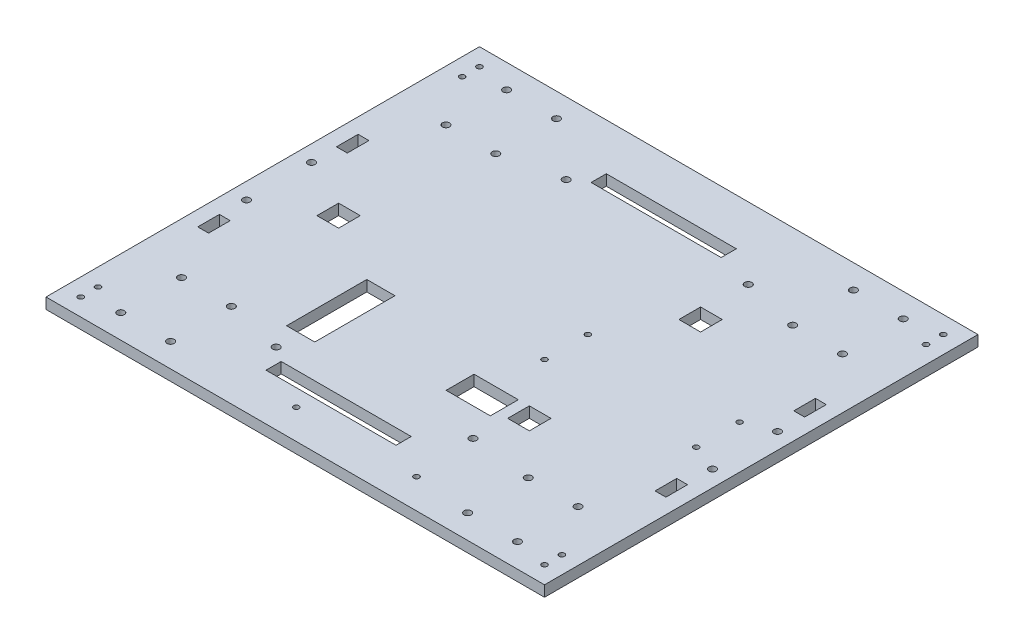
from build123d import *

# Parameters (mm, degrees)
SKETCH1_W                       = 230
SKETCH1_H                       = 200
EXTRUDE1_DEPTH                  = 5
SKETCH3_R                       = 1.65
SKETCH3_W                       = 60
SKETCH3_H                       = 7
SKETCH3_W_2                     = 13
SKETCH3_H_2                     = 37
EXTRUDE2_DEPTH                  = 5
SKIZZE1_R                       = 1.25
SCHNITT_LINEAR_AUSTRAGEN1_DEPTH = 10
SKIZZE3_R                       = 1.25
SCHNITT_LINEAR_AUSTRAGEN3_DEPTH = 5
SKIZZE4_R                       = 1.65
SKIZZE4_W                       = 5
SKIZZE4_H                       = 10
SCHNITT_LINEAR_AUSTRAGEN4_DEPTH = 10
SKIZZE5_R                       = 1.25
SCHNITT_LINEAR_AUSTRAGEN5_DEPTH = 10
SKIZZE6_W                       = 20.4
SKIZZE6_H                       = 12.9
SCHNITT_LINEAR_AUSTRAGEN6_DEPTH = 10
SKIZZE7_W                       = 10
SKIZZE7_H                       = 10
SCHNITT_LINEAR_AUSTRAGEN7_DEPTH = 10
SKIZZE8_W                       = 10
SKIZZE8_H                       = 10
SCHNITT_LINEAR_AUSTRAGEN8_DEPTH = 10


with BuildPart() as part:
    # Sketch1 → Extrude1 (new body)
    with BuildSketch(Plane(origin=(0, 0, 0), x_dir=(1, 0, 0), z_dir=(0, 1, 0))):
        with Locations((5, 8.694132839)):
            Rectangle(SKETCH1_W, SKETCH1_H)
    extrude(amount=EXTRUDE1_DEPTH)

    # Sketch3 → Extrude2 (cut)
    with BuildSketch(Plane(origin=(0, 5, 0), x_dir=(1, 0, 0), z_dir=(0, 1, 0))):
        with Locations((-86.5, 97.694132839)):
            Circle(SKETCH3_R)
        with Locations((-63.5, 97.694132839)):
            Circle(SKETCH3_R)
        with Locations((-86.5, 69.694132839)):
            Circle(SKETCH3_R)
        with Locations((-63.5, 69.694132839)):
            Circle(SKETCH3_R)
        with Locations((-86.5, -52.305867161)):
            Circle(SKETCH3_R)
        with Locations((-63.5, -52.305867161)):
            Circle(SKETCH3_R)
        with Locations((-86.5, -80.305867161)):
            Circle(SKETCH3_R)
        with Locations((-63.5, -80.305867161)):
            Circle(SKETCH3_R)
        with Locations((73.5, -52.305867161)):
            Circle(SKETCH3_R)
        with Locations((96.5, -52.305867161)):
            Circle(SKETCH3_R)
        with Locations((73.5, -80.305867161)):
            Circle(SKETCH3_R)
        with Locations((96.5, -80.305867161)):
            Circle(SKETCH3_R)
        with Locations((73.5, 97.694132839)):
            Circle(SKETCH3_R)
        with Locations((96.5, 97.694132839)):
            Circle(SKETCH3_R)
        with Locations((73.5, 69.694132839)):
            Circle(SKETCH3_R)
        with Locations((96.5, 69.694132839)):
            Circle(SKETCH3_R)
        with Locations((-36.9, -58.205867161)):
            Circle(SKETCH3_R)
        with Locations((-36.9, 75.594132839)):
            Circle(SKETCH3_R)
        with Locations((47, 75.694132839)):
            Circle(SKETCH3_R)
        with Locations((45, -49.305867161)):
            Circle(SKETCH3_R)
        with Locations((0, 83.694132839)):
            Rectangle(SKETCH3_W, SKETCH3_H)
        with Locations((0, -66.305867161)):
            Rectangle(SKETCH3_W, SKETCH3_H)
        with Locations((-36.5, -28.805867161)):
            Rectangle(SKETCH3_W_2, SKETCH3_H_2)
    extrude(amount=-EXTRUDE2_DEPTH, mode=Mode.SUBTRACT)

    # Skizze1 → Schnitt-Linear austragen1 (cut)
    with BuildSketch(Plane(origin=(0, 5, 0), x_dir=(1, 0, 0), z_dir=(0, 1, 0))):
        with Locations((-102, 100.694132839)):
            Circle(SKIZZE1_R)
        with Locations((-102, -83.305867161)):
            Circle(SKIZZE1_R)
        with Locations((112, -83.305867161)):
            Circle(SKIZZE1_R)
        with Locations((112, 100.694132839)):
            Circle(SKIZZE1_R)
        with Locations((-102, -75.305867161)):
            Circle(SKIZZE1_R)
        with Locations((-102, 92.694132839)):
            Circle(SKIZZE1_R)
        with Locations((112, 92.694132839)):
            Circle(SKIZZE1_R)
        with Locations((112, -75.305867161)):
            Circle(SKIZZE1_R)
    extrude(amount=-SCHNITT_LINEAR_AUSTRAGEN1_DEPTH, mode=Mode.SUBTRACT)

    # Skizze3 → Schnitt-Linear austragen3 (cut)
    with BuildSketch(Plane(origin=(0, 5, 0), x_dir=(1, 0, 0), z_dir=(0, 1, 0))):
        with Locations((-8.221682518, -77.643318078)):
            Circle(SKIZZE3_R)
        with Locations((47.278317482, -77.643318078)):
            Circle(SKIZZE3_R)
    extrude(amount=-SCHNITT_LINEAR_AUSTRAGEN3_DEPTH, mode=Mode.SUBTRACT)

    # Skizze4 → Schnitt-Linear austragen4 (cut)
    with BuildSketch(Plane(origin=(0, 5, 0), x_dir=(1, 0, 0), z_dir=(0, 1, 0))):
        with Locations((112.5, 23.694132839)):
            Circle(SKIZZE4_R)
        with Locations((112.5, -6.305867161)):
            Circle(SKIZZE4_R)
        with Locations((-102.5, 23.694132839)):
            Circle(SKIZZE4_R)
        with Locations((-102.5, -6.305867161)):
            Circle(SKIZZE4_R)
        with Locations((110.5, -23.305867161)):
            Rectangle(SKIZZE4_W, SKIZZE4_H)
        with Locations((110.5, 40.694132839)):
            Rectangle(SKIZZE4_W, SKIZZE4_H)
        with Locations((-100.5, 40.694132839)):
            Rectangle(SKIZZE4_W, SKIZZE4_H)
        with Locations((-100.5, -23.305867161)):
            Rectangle(SKIZZE4_W, SKIZZE4_H)
    extrude(amount=-SCHNITT_LINEAR_AUSTRAGEN4_DEPTH, mode=Mode.SUBTRACT)

    # Skizze5 → Schnitt-Linear austragen5 (cut)
    with BuildSketch(Plane(origin=(0, 5, 0), x_dir=(1, 0, 0), z_dir=(0, 1, 0))):
        with Locations((100, 18.694132839)):
            Circle(SKIZZE5_R)
        with Locations((100, -1.305867161)):
            Circle(SKIZZE5_R)
        with Locations((30, 18.694132839)):
            Circle(SKIZZE5_R)
        with Locations((30, -1.305867161)):
            Circle(SKIZZE5_R)
    extrude(amount=-SCHNITT_LINEAR_AUSTRAGEN5_DEPTH, mode=Mode.SUBTRACT)

    # Skizze6 → Schnitt-Linear austragen6 (cut)
    with BuildSketch(Plane(origin=(0, 5, 0), x_dir=(1, 0, 0), z_dir=(0, 1, 0))):
        with Locations((29.8, -29.855867161)):
            Rectangle(SKIZZE6_W, SKIZZE6_H)
    extrude(amount=-SCHNITT_LINEAR_AUSTRAGEN6_DEPTH, mode=Mode.SUBTRACT)

    # Skizze7 → Schnitt-Linear austragen7 (cut)
    with BuildSketch(Plane(origin=(0, 5, 0), x_dir=(1, 0, 0), z_dir=(0, 1, 0))):
        with Locations((-75, 8.694132839)):
            Rectangle(SKIZZE7_W, SKIZZE7_H)
    extrude(amount=-SCHNITT_LINEAR_AUSTRAGEN7_DEPTH, mode=Mode.SUBTRACT)

    # Skizze8 → Schnitt-Linear austragen8 (cut)
    with BuildSketch(Plane(origin=(0, 5, 0), x_dir=(1, 0, 0), z_dir=(0, 1, 0))):
        with Locations((50, 50.694132839)):
            Rectangle(SKIZZE8_W, SKIZZE8_H)
        with Locations((50, -28.305867161)):
            Rectangle(SKIZZE8_W, SKIZZE8_H)
    extrude(amount=-SCHNITT_LINEAR_AUSTRAGEN8_DEPTH, mode=Mode.SUBTRACT)


solid = part.part
